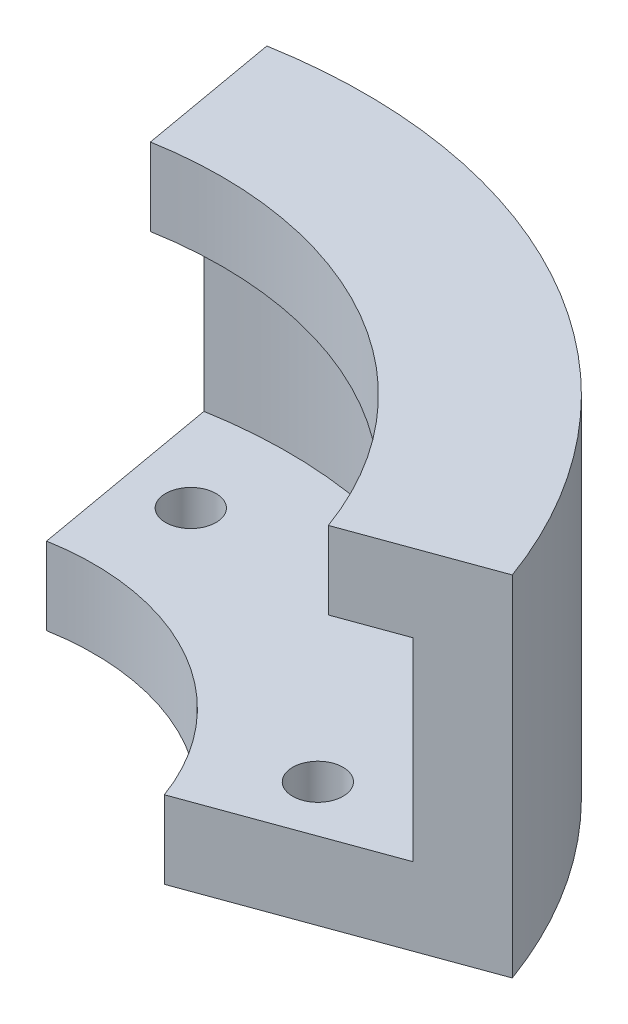
from build123d import *

# Parameters (mm, degrees)
BOSS_EXTRUDE1_DEPTH = 12.7
SHELL1_T            = 5.08
SKETCH1_3_R         = 1.651
SKETCH1_3_R_2       = 1.6509999999999996
CUT_EXTRUDE1_DEPTH  = 12.192
SKETCH2_R           = 24.765
CUT_EXTRUDE2_DEPTH  = 5.08


with BuildPart() as part:
    # Sketch1 → Boss-Extrude1 (new body)
    with BuildSketch(Plane(origin=(0, 0, 0), x_dir=(1, 0, 0), z_dir=(0, 1, 0))):
        with BuildLine():
            ThreePointArc((25.18661681826276, 14.541500000000127), (14.541499999999942, 25.186616818262866), (1.78e-15, 29.083000000000002))
            Line((0, 29.083000000000002), (0, 24.384))
            ThreePointArc((-2.409e-14, 24.384), (1.1674332957389815, 23.900433295739), (1.651, 22.733))
            ThreePointArc((1.651, 22.733), (1.1674332957389804, 21.565566704261002), (-2.523e-14, 21.082))
            Line((0, 21.082), (0, 16.383))
            ThreePointArc((1e-15, 16.383000000000003), (8.191499999999966, 14.188094190200482), (14.188094190200419, 8.191500000000074))
            Line((14.188094190200417, 8.191500000000072), (18.257547562583486, 10.541000000000096))
            ThreePointArc((18.257547562583472, 10.541000000000121), (18.86185550423157, 12.796307941648193), (21.11716344587966, 12.192000000000167))
            Line((21.117163445879694, 12.19200000000011), (25.18661681826275, 14.541500000000124))
        make_face()
        with BuildLine():
            ThreePointArc((1.651, 22.733), (1.1674332957389815, 23.900433295739), (-2.409e-14, 24.384))
            Line((0, 24.384), (0, 21.082))
            ThreePointArc((-2.523e-14, 21.082), (1.1674332957389804, 21.565566704261002), (1.651, 22.733))
        make_face()
        with BuildLine():
            Line((0, 21.082), (0, 24.384))
            ThreePointArc((-2.409e-14, 24.384), (-1.651, 22.733), (-2.523e-14, 21.082))
        make_face()
        with BuildLine():
            Line((0, 24.384), (0, 29.083000000000002))
            ThreePointArc((1.78e-15, 29.083000000000002), (-2.5347504663301574, 28.972330404602236), (-5.050209951087366, 28.641163880854045))
            Line((-5.050209951087367, 28.641163880854048), (-2.8448780947173375, 16.134105417599))
            ThreePointArc((-2.8448780947173375, 16.134105417599006), (-1.4278725334348923, 16.320657738837067), (1e-15, 16.383000000000003))
            Line((0, 16.383), (0, 21.082))
            ThreePointArc((-2.523e-14, 21.082), (-1.651, 22.733), (-2.409e-14, 24.384))
        make_face()
        with BuildLine():
            ThreePointArc((21.338355504231593, 11.366500000000098), (21.282099043434833, 11.793810243464398), (21.11716344587966, 12.192000000000167))
            Line((21.117163445879694, 12.19200000000011), (18.257547562583486, 10.541000000000096))
            ThreePointArc((18.257547562583472, 10.541000000000121), (20.11466574769584, 9.771756460796842), (21.338355504231593, 11.366500000000098))
        make_face()
        with BuildLine():
            Line((18.257547562583486, 10.541000000000096), (21.117163445879694, 12.19200000000011))
            ThreePointArc((21.11716344587966, 12.192000000000167), (18.86185550423157, 12.796307941648193), (18.257547562583472, 10.541000000000121))
        make_face()
        with BuildLine():
            ThreePointArc((27.32908049031651, 9.9469718283406), (26.358149370386823, 12.291006906204913), (25.18661681826276, 14.541500000000127))
            Line((25.18661681826275, 14.541500000000124), (21.117163445879694, 12.19200000000011))
            ThreePointArc((21.11716344587966, 12.192000000000167), (21.282099043434833, 11.793810243464398), (21.338355504231593, 11.366500000000098))
            ThreePointArc((21.338355504231593, 11.366500000000098), (20.11466574769584, 9.771756460796842), (18.257547562583472, 10.541000000000121))
            Line((18.257547562583486, 10.541000000000096), (14.188094190200417, 8.191500000000072))
            ThreePointArc((14.188094190200419, 8.191500000000074), (14.848040475021392, 6.923754982097979), (15.394984206335495, 5.603316008104555))
            Line((15.394984206335494, 5.603316008104554), (27.329080490316503, 9.946971828340597))
        make_face()
    extrude(amount=BOSS_EXTRUDE1_DEPTH)

    # Shell1
    shell1_openings = [part.faces().sort_by_distance(p)[0] for p in [
        (21.362032348, 6.35, -7.775143918),
        (8.1915, 6.35, -14.18809419),
        (-3.947544023, 6.35, -22.387634649),
    ]]
    offset(amount=SHELL1_T, openings=shell1_openings, kind=Kind.INTERSECTION)

    # Sketch1_3 → Cut-Extrude1 (cut)
    with BuildSketch(Plane(origin=(0, 0, 0), x_dir=(1, 0, 0), z_dir=(0, 1, 0))):
        with Locations(Location((0, 22.733, 0), (0, 0, 270))):
            Circle(SKETCH1_3_R)
        with Locations(Location((19.687355504231594, 11.366500000000098, 0), (0, 0, 270))):
            Circle(SKETCH1_3_R_2)
    extrude(amount=-CUT_EXTRUDE1_DEPTH, mode=Mode.SUBTRACT)

    # Sketch2 → Cut-Extrude2 (cut)
    with BuildSketch(Plane(origin=(0, 17.78, 0), x_dir=(1, 0, 0), z_dir=(0, 1, 0))):
        Circle(SKETCH2_R)
    extrude(amount=-CUT_EXTRUDE2_DEPTH, mode=Mode.SUBTRACT)


solid = part.part
